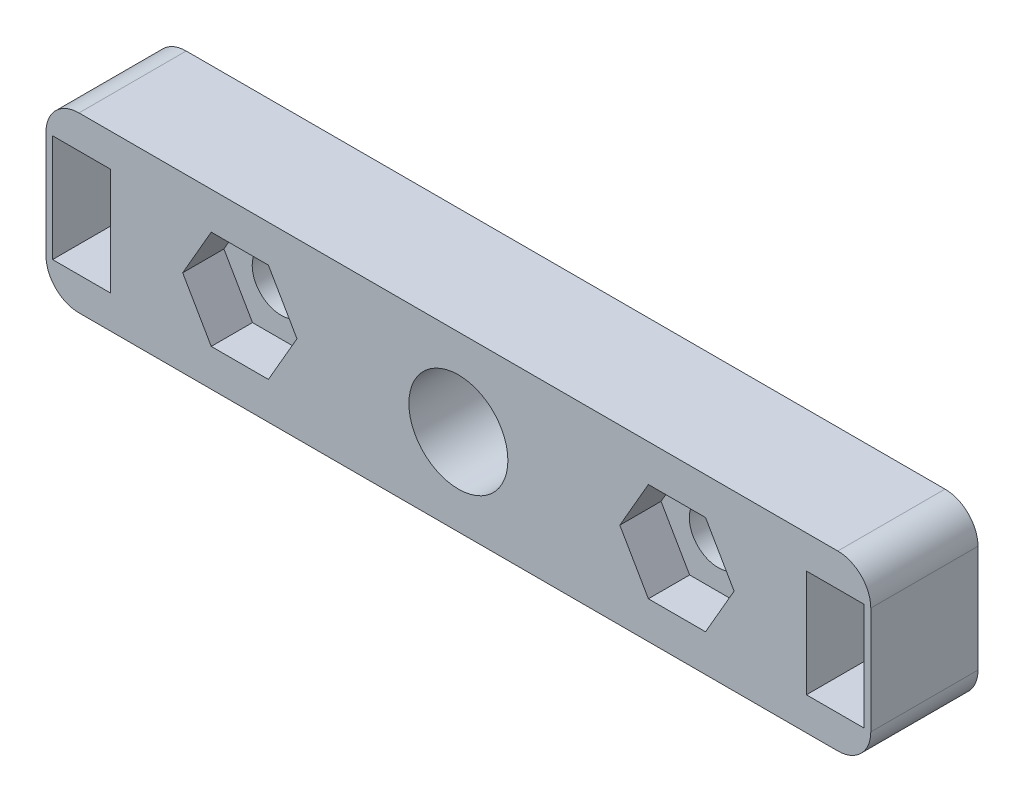
from build123d import *

# Parameters (mm, degrees)
SKETCH_1_W          = 50
SKETCH_1_H          = 10.5
EXTRUDE_1_DEPTH     = 17
SKETCH_2_W          = 36
SKETCH_2_H          = 3.5
CUT_EXTRUDE_1_DEPTH = 10
CUT_EXTRUDE_2_DEPTH = 10.5
SKETCH_4_W          = 3.5
SKETCH_4_H          = 6.5
CUT_EXTRUDE_3_DEPTH = 6.5
FILLET_1_R          = 2
SKETCH_6_R          = 3
SKETCH_6_R_2        = 1.75
CUT_EXTRUDE_4_DEPTH = 18
CUT_EXTRUDE_5_DEPTH = 11
CUT_EXTRUDE_6_DEPTH = 3
SKETCH_9_W          = 58.421136066
SKETCH_9_H          = 24.245128271
CUT_EXTRUDE_7_DEPTH = 11.5


with BuildPart() as part:
    # ｽｹｯﾁ1 → ﾎﾞｽ - 押し出し1 (new body)
    with BuildSketch(Plane.XY):
        with Locations((25, 5.25)):
            Rectangle(SKETCH_1_W, SKETCH_1_H)
    extrude(amount=EXTRUDE_1_DEPTH)

    # ｽｹｯﾁ2 → ｶｯﾄ - 押し出し1 (cut)
    with BuildSketch(Plane.XY.offset(17)):
        with Locations((25, 5.25)):
            Rectangle(SKETCH_2_W, SKETCH_2_H)
    extrude(amount=-CUT_EXTRUDE_1_DEPTH, mode=Mode.SUBTRACT)

    # ｽｹｯﾁ3 → ｶｯﾄ - 押し出し2 (cut)
    with BuildSketch(Plane.XZ):
        Polygon((1, 17), (3, 12), (7, 12), (17, 17), align=None)
        Polygon((33, 17), (43, 12), (47, 12), (49, 17), align=None)
    extrude(amount=-CUT_EXTRUDE_2_DEPTH, mode=Mode.SUBTRACT)

    # ｽｹｯﾁ4 → ｶｯﾄ - 押し出し3 (cut)
    with BuildSketch(Plane(origin=(0, 0, 0), x_dir=(-1, 0, 0), z_dir=(0, 0, -1))):
        with Locations((-2.15, 5.25)):
            Rectangle(SKETCH_4_W, SKETCH_4_H)
        with Locations((-47.85, 5.25)):
            Rectangle(SKETCH_4_W, SKETCH_4_H)
    extrude(amount=-CUT_EXTRUDE_3_DEPTH, mode=Mode.SUBTRACT)

    # ﾌｨﾚｯﾄ1
    fillet_1_edges = [part.edges().sort_by_distance(p)[0] for p in [
        (0, 0, 8.5),
        (0, 10.5, 8.5),
        (50, 0, 8.5),
        (50, 10.5, 8.5),
    ]]
    fillet(fillet_1_edges, radius=FILLET_1_R)

    # ｽｹｯﾁ6 → ｶｯﾄ - 押し出し4 (cut, through all)
    with BuildSketch(Plane(origin=(0, 0, 0), x_dir=(-1, 0, 0), z_dir=(0, 0, -1))):
        with Locations((-25, 5.25)):
            Circle(SKETCH_6_R)
        with Locations((-11.75, 5.25)):
            Circle(SKETCH_6_R_2)
        with Locations((-38.25, 5.25)):
            Circle(SKETCH_6_R_2)
    extrude(amount=-CUT_EXTRUDE_4_DEPTH, mode=Mode.SUBTRACT)

    # ｽｹｯﾁ7 → ｶｯﾄ - 押し出し5 (cut, through all)
    with BuildSketch(Plane.XY.offset(7)):
        Polygon((34.785898385, 5.25), (36.517949192, 2.25), (39.982050808, 2.25), (41.714101615, 5.25), (39.982050808, 8.25), (36.517949192, 8.25), align=None)
        Polygon((13.482050808, 8.25), (15.214101615, 5.25), (13.482050808, 2.25), (10.017949192, 2.25), (8.285898385, 5.25), (10.017949192, 8.25), align=None)
    extrude(amount=CUT_EXTRUDE_5_DEPTH, mode=Mode.SUBTRACT)

    # ｽｹｯﾁ8 → ｶｯﾄ - 押し出し6 (cut)
    with BuildSketch(Plane.XY.offset(7)):
        Polygon((36.517949192, 2.25), (39.982050808, 2.25), (41.714101615, 5.25), (39.982050808, 8.25), (36.517949192, 8.25), (34.785898385, 5.25), align=None)
        Polygon((15.214101615, 5.25), (13.482050808, 2.25), (10.017949192, 2.25), (8.285898385, 5.25), (10.017949192, 8.25), (13.482050808, 8.25), align=None)
    extrude(amount=-CUT_EXTRUDE_6_DEPTH, mode=Mode.SUBTRACT)

    # ｽｹｯﾁ9 → ｶｯﾄ - 押し出し7 (cut, through all)
    with BuildSketch(Plane(origin=(0, 0, 6.5), x_dir=(-1, 0, 0), z_dir=(0, 0, -1))):
        with Locations((-24.970881096, 5.810967265)):
            Rectangle(SKETCH_9_W, SKETCH_9_H)
    extrude(amount=-CUT_EXTRUDE_7_DEPTH, mode=Mode.SUBTRACT)


solid = part.part
